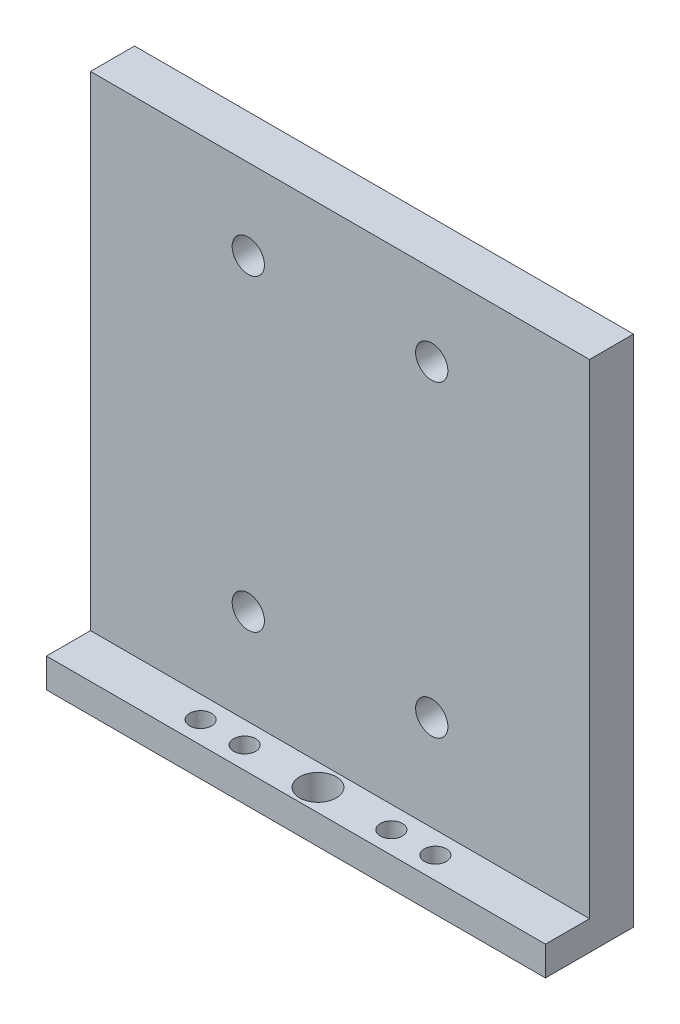
from build123d import *

# Parameters (mm, degrees)
BOSS_EXTRUDE1_DEPTH = 34
SKETCH2_R           = 1.1
CUT_EXTRUDE1_DEPTH  = 4
SKETCH3_R           = 1.25
SKETCH3_R_2         = 0.75
CUT_EXTRUDE2_DEPTH  = 3


with BuildPart() as part:
    # Sketch1 → Boss-Extrude1 (new body)
    with BuildSketch(Plane(origin=(0, 0, 0), x_dir=(0, 0, -1), z_dir=(1, 0, 0))):
        Polygon((0, 0), (6, 0), (6, 35), (3, 35), (3, 2), (0, 2), align=None)
    extrude(amount=BOSS_EXTRUDE1_DEPTH)

    # Sketch2 → Cut-Extrude1 (cut, through all)
    with BuildSketch(Plane.XY.offset(-3)):
        with Locations((23.25, 29.5)):
            Circle(SKETCH2_R)
        with Locations((10.75, 29.5)):
            Circle(SKETCH2_R)
        with Locations((10.75, 8.5)):
            Circle(SKETCH2_R)
        with Locations((23.25, 8.5)):
            Circle(SKETCH2_R)
    extrude(amount=-CUT_EXTRUDE1_DEPTH, mode=Mode.SUBTRACT)

    # Sketch3 → Cut-Extrude2 (cut, through all)
    with BuildSketch(Plane(origin=(0, 2, 0), x_dir=(1, 0, 0), z_dir=(0, 1, 0))):
        with Locations((17, 1.5)):
            Circle(SKETCH3_R)
        with Locations((22, 1.5)):
            Circle(SKETCH3_R_2)
        with Locations((25, 1.5)):
            Circle(SKETCH3_R_2)
        with Locations((12, 1.5)):
            Circle(SKETCH3_R_2)
        with Locations((9, 1.5)):
            Circle(SKETCH3_R_2)
    extrude(amount=-CUT_EXTRUDE2_DEPTH, mode=Mode.SUBTRACT)


solid = part.part
